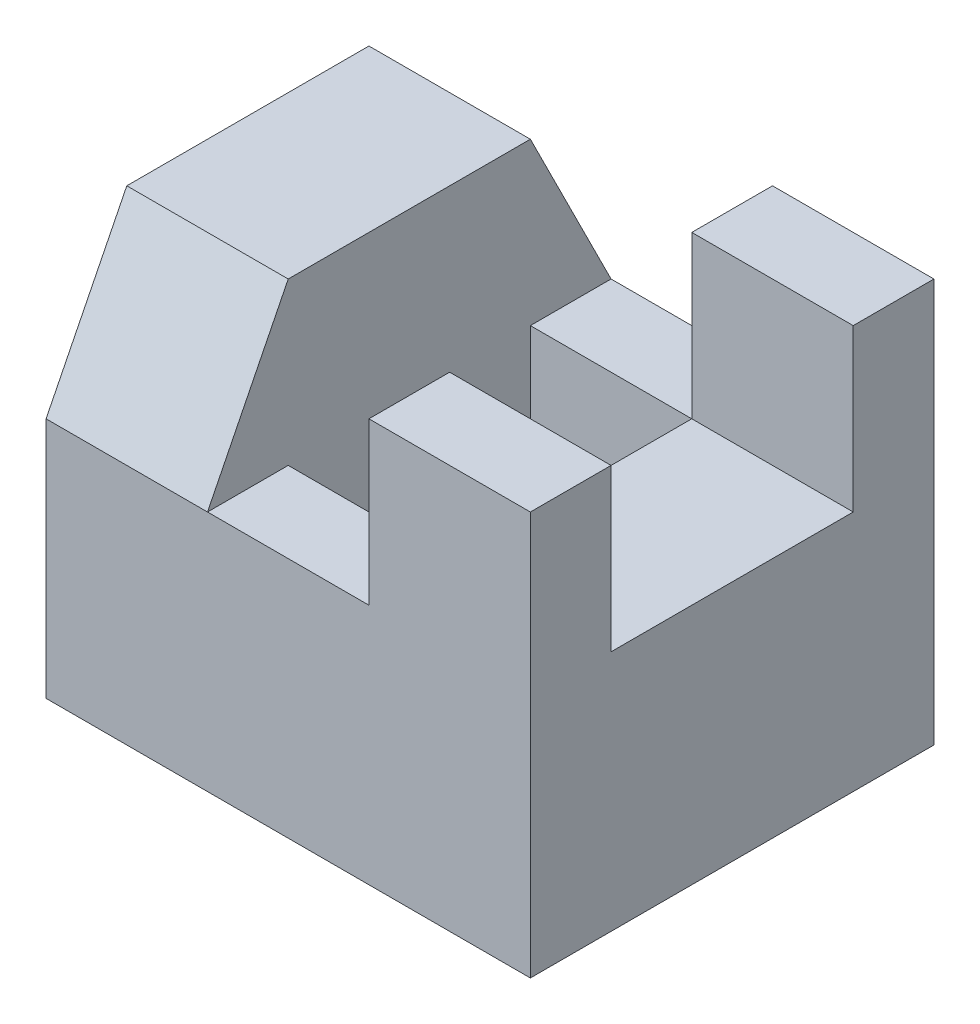
from build123d import *

# Parameters (mm, degrees)
SKETCH1_W           = 30
SKETCH1_H           = 25
BOSS_EXTRUDE1_DEPTH = 25
CUT_EXTRUDE1_DEPTH  = 10
SKETCH3_W           = 10
SKETCH3_H           = 25
CUT_EXTRUDE3_DEPTH  = 10
SKETCH5_W           = 10
SKETCH5_H           = 15
CUT_EXTRUDE4_DEPTH  = 30
SKETCH6_W           = 10
SKETCH6_H           = 15
CUT_EXTRUDE5_DEPTH  = 10


with BuildPart() as part:
    # Sketch1 → Boss-Extrude1 (new body)
    with BuildSketch(Plane.XY):
        with Locations((15, 12.5)):
            Rectangle(SKETCH1_W, SKETCH1_H)
    extrude(amount=BOSS_EXTRUDE1_DEPTH)

    # Sketch2 → Cut-Extrude1 (cut)
    with BuildSketch(Plane.ZY):
        Polygon((0, 15), (5, 25), (0, 25), align=None)
        Polygon((25, 25), (20, 25), (25, 15), align=None)
    extrude(amount=-CUT_EXTRUDE1_DEPTH, mode=Mode.SUBTRACT)

    # Sketch3 → Cut-Extrude3 (cut)
    with BuildSketch(Plane(origin=(0, 25, 0), x_dir=(1, 0, 0), z_dir=(0, 1, 0))):
        with Locations((15, -12.5)):
            Rectangle(SKETCH3_W, SKETCH3_H)
    extrude(amount=-CUT_EXTRUDE3_DEPTH, mode=Mode.SUBTRACT)

    # Sketch5 → Cut-Extrude4 (cut)
    with BuildSketch(Plane(origin=(0, 15, 0), x_dir=(1, 0, 0), z_dir=(0, 1, 0))):
        with Locations((15, -12.5)):
            Rectangle(SKETCH5_W, SKETCH5_H)
    extrude(amount=-CUT_EXTRUDE4_DEPTH, mode=Mode.SUBTRACT)

    # Sketch6 → Cut-Extrude5 (cut)
    with BuildSketch(Plane(origin=(0, 25, 0), x_dir=(1, 0, 0), z_dir=(0, 1, 0))):
        with Locations((25, -12.5)):
            Rectangle(SKETCH6_W, SKETCH6_H)
    extrude(amount=-CUT_EXTRUDE5_DEPTH, mode=Mode.SUBTRACT)


solid = part.part
